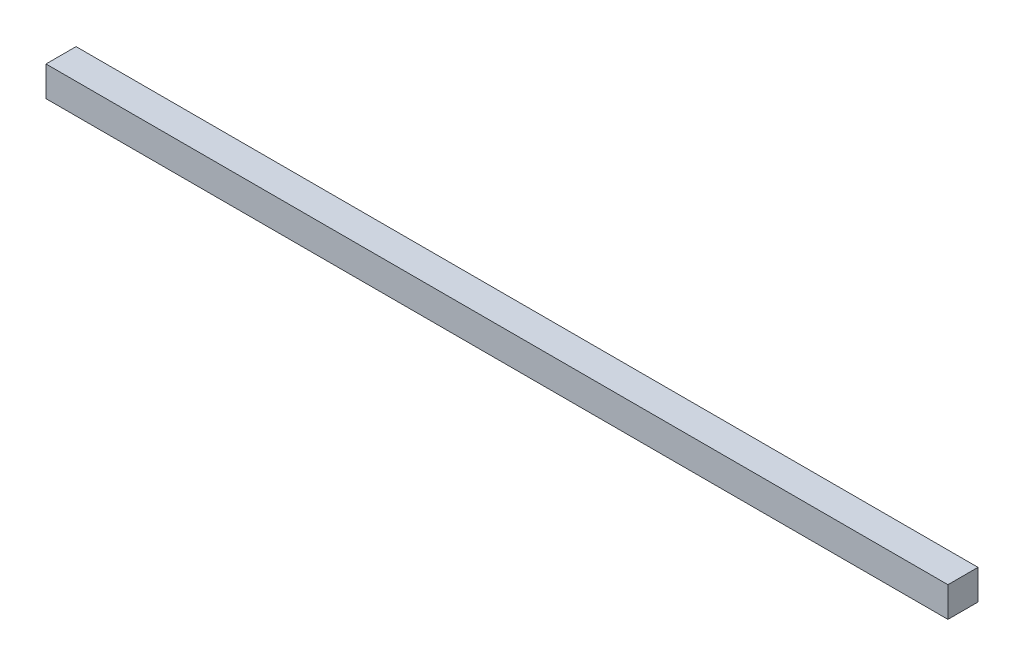
from build123d import *

# Parameters (mm, degrees)
ESQUISSE1_W        = 300
ESQUISSE1_H        = 10
BOSS_EXTRU_1_DEPTH = 10


with BuildPart() as part:
    # Esquisse1 → Boss.-Extru.1 (new body)
    with BuildSketch(Plane.XY):
        with Locations((86.933345127, 5.79962963)):
            Rectangle(ESQUISSE1_W, ESQUISSE1_H)
    extrude(amount=BOSS_EXTRU_1_DEPTH)


solid = part.part
